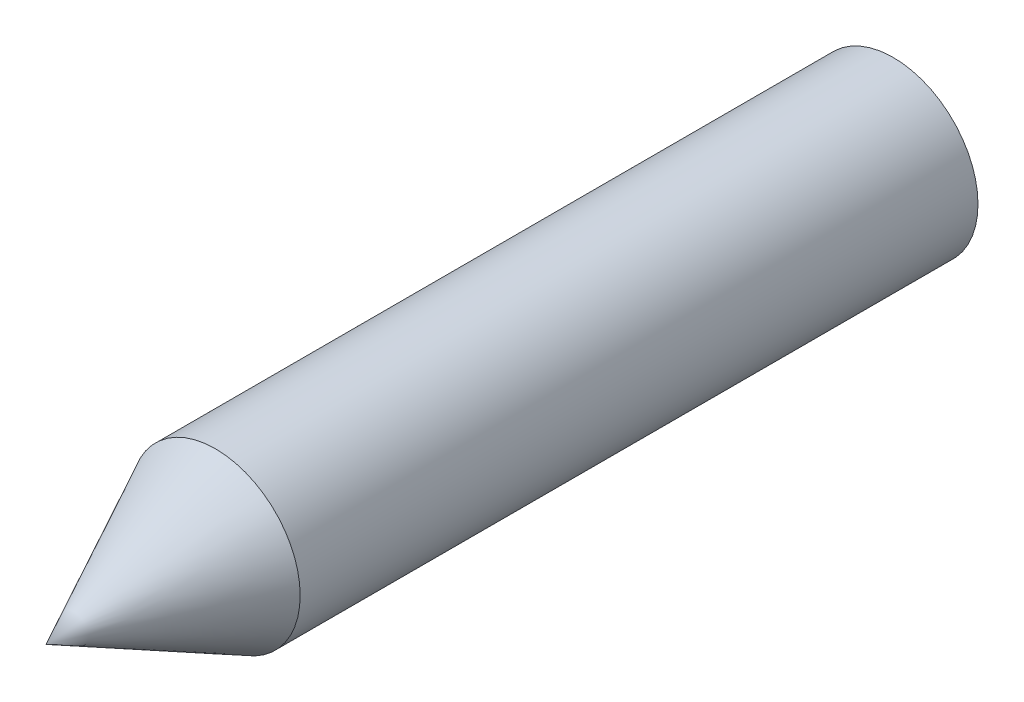
from build123d import *

# Parameters (mm, degrees)
SKETCH1_R           = 5
BOSS_EXTRUDE1_DEPTH = 40


with BuildPart() as part:
    # Sketch1 → Boss-Extrude1 (new body)
    with BuildSketch(Plane.XY):
        Circle(SKETCH1_R)
    extrude(amount=BOSS_EXTRUDE1_DEPTH)

    # Sketch2 → Revolve1 (revolve)
    with BuildSketch(Plane(origin=(0, 0, 0), x_dir=(1, 0, 0), z_dir=(0, 1, 0))):
        Polygon((0, -40), (-5, -40), (0, -50), align=None)
    revolve(axis=Axis((0, 0, 40), (0, 0, 1)))


solid = part.part
